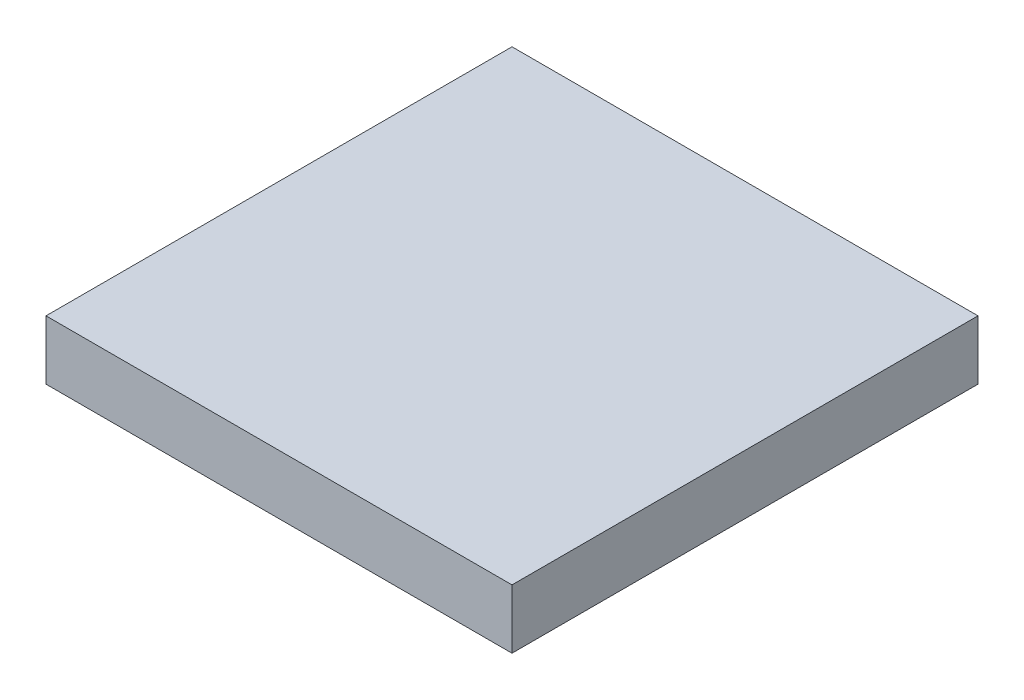
from build123d import *

# Parameters (mm, degrees)
SKETCH1_W           = 100
SKETCH1_H           = 100
BOSS_EXTRUDE1_DEPTH = 12.7


with BuildPart() as part:
    # Sketch1 → Boss-Extrude1 (new body)
    with BuildSketch(Plane(origin=(0, 0, 0), x_dir=(1, 0, 0), z_dir=(0, 1, 0))):
        Rectangle(SKETCH1_W, SKETCH1_H)
    extrude(amount=BOSS_EXTRUDE1_DEPTH)


solid = part.part
